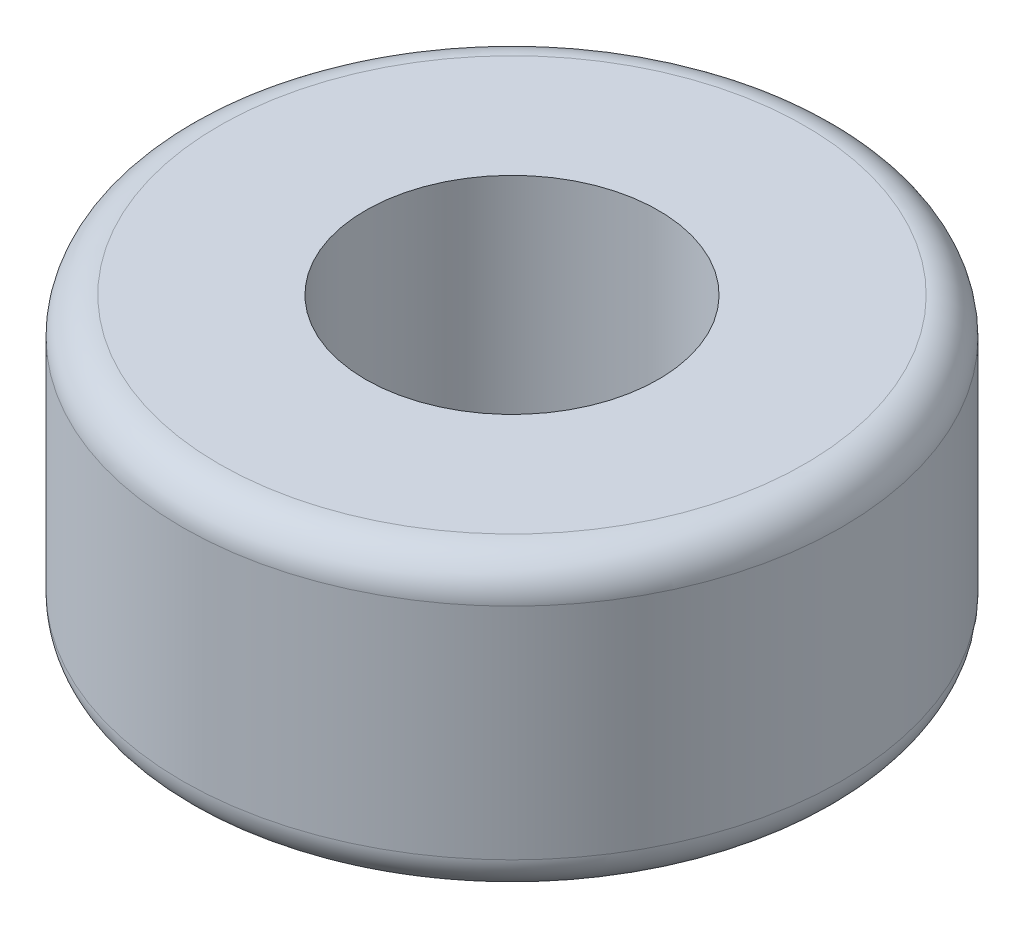
from build123d import *

# Parameters (mm, degrees)
SKETCH1_R           = 4.5
SKETCH1_R_2         = 2
BOSS_EXTRUDE1_DEPTH = 4
FILLET1_R           = 0.5


with BuildPart() as part:
    # Sketch1 → Boss-Extrude1 (new body)
    with BuildSketch(Plane(origin=(0, 0, 0), x_dir=(1, 0, 0), z_dir=(0, 1, 0))):
        Circle(SKETCH1_R)
        Circle(SKETCH1_R_2, mode=Mode.SUBTRACT)
    extrude(amount=BOSS_EXTRUDE1_DEPTH)

    # Fillet1
    fillet1_edges = [part.edges().sort_by_distance(p)[0] for p in [
        (-4.5, 0, 0),
        (-4.5, 4, 0),
    ]]
    fillet(fillet1_edges, radius=FILLET1_R)


solid = part.part
